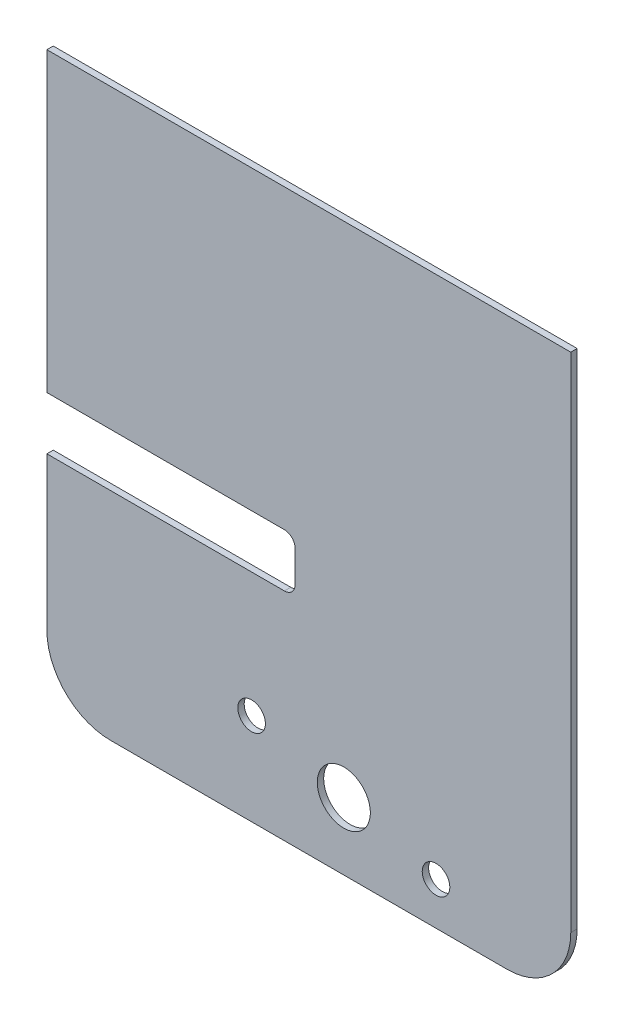
from build123d import *

# Parameters (mm, degrees)
ESQUISSE1_W             = 247
ESQUISSE1_H             = 267
BOSS_EXTRU_1_DEPTH      = 3
ESQUISSE3_R             = 6.5
ESQUISSE3_R_2           = 12.5
ENL_V_MAT_EXTRU_2_DEPTH = 3
ESQUISSE4_W             = 120
ESQUISSE4_H             = 25
ENL_V_MAT_EXTRU_3_DEPTH = 10
CONG_1_R                = 30
CONG_2_R                = 5


with BuildPart() as part:
    # Esquisse1 → Boss.-Extru.1 (new body)
    with BuildSketch(Plane.XY):
        Rectangle(ESQUISSE1_W, ESQUISSE1_H)
    extrude(amount=BOSS_EXTRU_1_DEPTH)

    # Esquisse3 → Enlèv. mat.-Extru.2 (cut)
    with BuildSketch(Plane(origin=(0, 0, 0), x_dir=(-1, 0, 0), z_dir=(0, 0, -1))):
        with Locations((-59.966662183, -113.5)):
            Circle(ESQUISSE3_R)
        with Locations((-16.5, -101.85314297)):
            Circle(ESQUISSE3_R_2)
        with Locations((26.966662183, -90.206285941)):
            Circle(ESQUISSE3_R)
    extrude(amount=-ENL_V_MAT_EXTRU_2_DEPTH, mode=Mode.SUBTRACT)

    # Esquisse4 → Enlèv. mat.-Extru.3 (cut)
    with BuildSketch(Plane(origin=(0, 0, 0), x_dir=(-1, 0, 0), z_dir=(0, 0, -1))):
        with Locations((66.5, -19)):
            Rectangle(ESQUISSE4_W, ESQUISSE4_H)
    extrude(amount=-ENL_V_MAT_EXTRU_3_DEPTH, mode=Mode.SUBTRACT)

    # Congé1
    cong_1_edges = [part.edges().sort_by_distance(p)[0] for p in [
        (123.5, -133.5, 1.5),
        (-123.5, -133.5, 1.5),
    ]]
    fillet(cong_1_edges, radius=CONG_1_R)

    # Congé2
    cong_2_edges = [part.edges().sort_by_distance(p)[0] for p in [
        (-6.5, -31.5, 1.5),
        (-6.5, -6.5, 1.5),
    ]]
    fillet(cong_2_edges, radius=CONG_2_R)


solid = part.part
